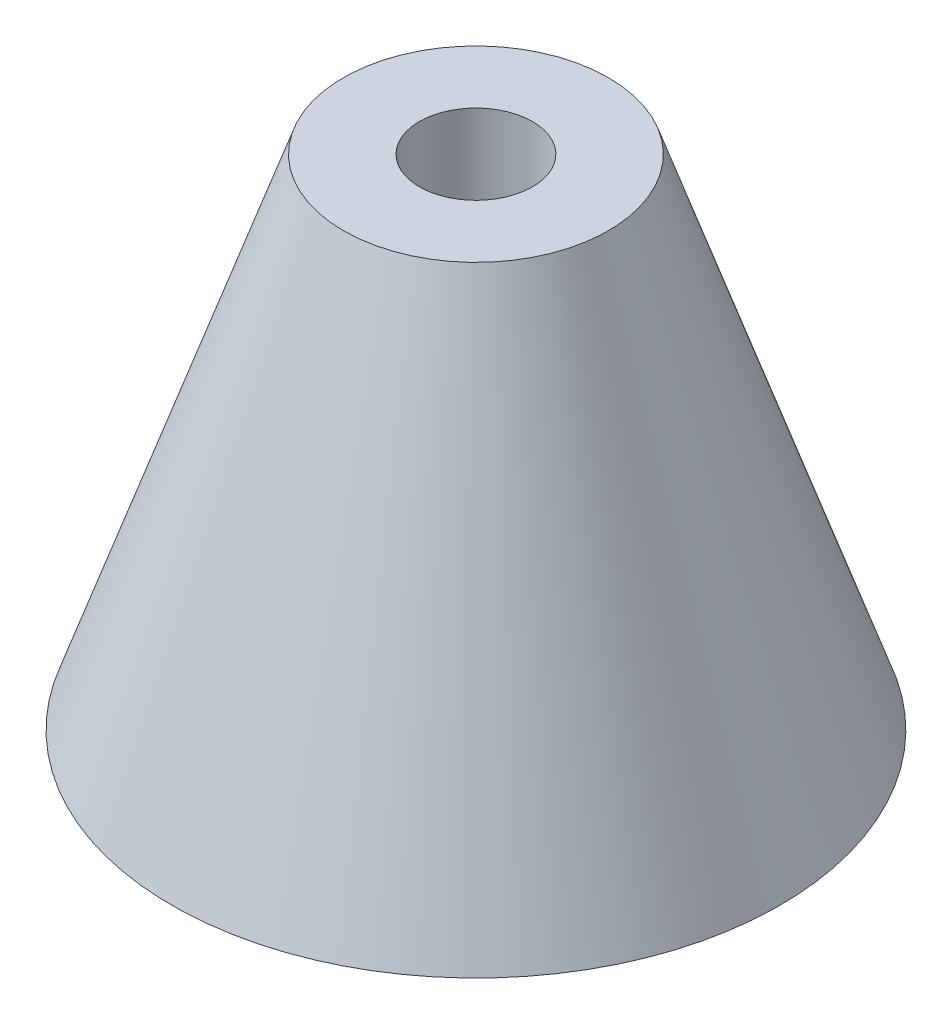
from build123d import *

# Parameters (mm, degrees)
CUT_EXTRUDE1_DEPTH = 3.0988


with BuildPart() as part:
    # Sketch1 → Revolve1 (revolve)
    with BuildSketch(Plane.XY):
        Polygon((12.7, 0), (2.3622, 0), (2.3622, 20.828), (5.5372, 20.828), align=None)
    revolve(axis=Axis((0, 0, 0), (0, 1, 0)))

    # Sketch2 → Cut-Extrude1 (cut)
    with BuildSketch(Plane.XZ):
        Polygon((0, 5.381943739), (-4.6609, 2.69097187), (-4.6609, -2.69097187), (0, -5.381943739), (4.6609, -2.69097187), (4.6609, 2.69097187), align=None)
    extrude(amount=-CUT_EXTRUDE1_DEPTH, mode=Mode.SUBTRACT)


solid = part.part
